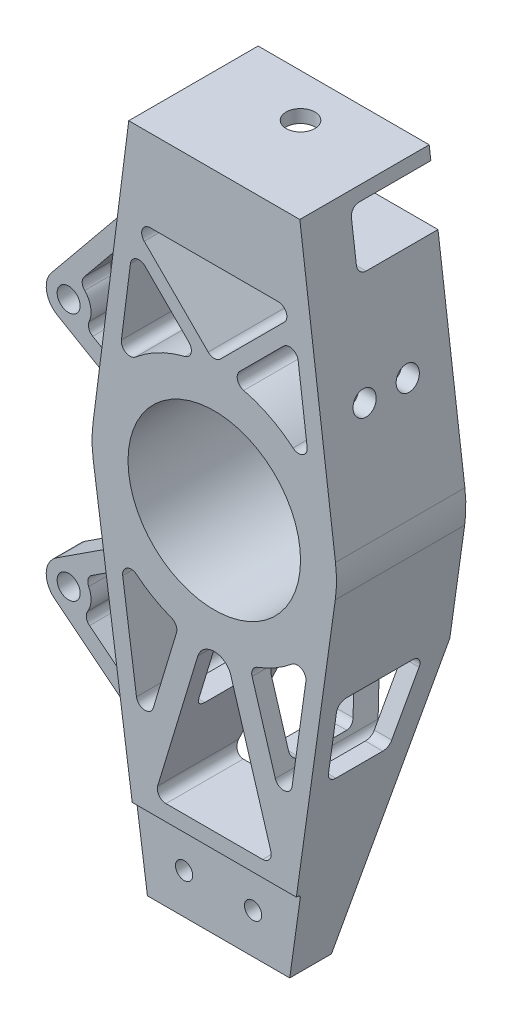
from build123d import *

# Parameters (mm, degrees)
SKETCH1_R                      = 30
SKETCH1_R_2                    = 3
BOSS_EXTRUDE1_DEPTH            = 22.5
CUT_EXTRUDE1_START             = 6.7
SKETCH2_W                      = 43.5
SKETCH2_H                      = 28
CUT_EXTRUDE1_DEPTH             = 45
CUT_EXTRUDE3_DEPTH             = 43.5
CUT_EXTRUDE3_DEPTH_BACK        = 43.5
SKETCH7_R                      = 5
CUT_EXTRUDE4_DEPTH             = 28.5
CUT_EXTRUDE5_REACH             = 44.5
CUT_EXTRUDE5_DIRECTION_2_DEPTH = 43.5
CUT_EXTRUDE6_START             = 30.728059
SKETCH10_R                     = 4
CUT_EXTRUDE6_DEPTH             = 7.070855
SKETCH12_R                     = 4
BOSS_EXTRUDE2_DEPTH            = 10


with BuildPart() as part:
    # Sketch1 → Boss-Extrude1 (new body, symmetric)
    with BuildSketch(Plane.XY):
        with BuildLine():
            Line((-29.75, 102.5), (-42.157330806, 5.38604301))
            ThreePointArc((-42.157330806, 5.38604301), (-42.499156405, -0.267777651), (-42.086113863, -5.916842057))
            Line((-42.086113863, -5.916842057), (-37.836662433, -36.142914512))
            Line((-37.836662433, -36.142914512), (-30.179572712, -90.607297158))
            Line((-30.179572712, -90.607297158), (-24.75, -129.227495762))
            Line((-24.75, -129.227495762), (24.75, -129.227495762))
            Line((24.75, -129.227495762), (42.086113863, -5.916842057))
            ThreePointArc((42.086113863, -5.916842057), (42.499156405, -0.267777651), (42.157330806, 5.38604301))
            Line((42.157330806, 5.38604301), (29.75, 102.5))
            Line((29.75, 102.5), (-29.75, 102.5))
        make_face()
        Circle(SKETCH1_R, mode=Mode.SUBTRACT)
        with Locations((-12, -115.227495762)):
            Circle(SKETCH1_R_2, mode=Mode.SUBTRACT)
        with Locations((12, -115.227495762)):
            Circle(SKETCH1_R_2, mode=Mode.SUBTRACT)
        with BuildLine():
            Line((-31.858021287, -35.571287293), (-27.062097865, -69.684379585))
            ThreePointArc((-27.062097865, -69.684379585), (-24.322273449, -72.257816506), (-21.219861823, -70.135492892))
            Line((-21.219861823, -70.135492892), (-13.147714601, -43.455581929))
            ThreePointArc((-13.147714601, -43.455581929), (-13.329157036, -41.258708643), (-14.96295738, -39.778887698))
            ThreePointArc((-14.96295738, -39.778887698), (-21.258144353, -36.801376315), (-26.982583804, -32.835806237))
            ThreePointArc((-26.982583804, -32.835806237), (-30.355185437, -32.537308543), (-31.858021287, -35.571287293))
        make_face(mode=Mode.SUBTRACT)
        with BuildLine():
            Line((31.858021287, -35.571287293), (27.062097865, -69.684379585))
            ThreePointArc((27.062097865, -69.684379585), (24.322273449, -72.257816506), (21.219861823, -70.135492892))
            Line((21.219861823, -70.135492892), (13.147714601, -43.455581929))
            ThreePointArc((13.147714601, -43.455581929), (13.329157036, -41.258708643), (14.96295738, -39.778887698))
            ThreePointArc((14.96295738, -39.778887698), (21.258144353, -36.801376315), (26.982583804, -32.835806237))
            ThreePointArc((26.982583804, -32.835806237), (30.355185437, -32.537308543), (31.858021287, -35.571287293))
        make_face(mode=Mode.SUBTRACT)
        with BuildLine():
            Line((-29.161510987, 59.761597506), (-32.303727483, 35.167018507))
            ThreePointArc((-32.303727483, 35.167018507), (-30.762779632, 32.152217955), (-27.394207157, 32.493190275))
            ThreePointArc((-27.394207157, 32.493190275), (-19.319896855, 37.85487532), (-10.240768442, 41.247747353))
            ThreePointArc((-10.240768442, 41.247747353), (-8.073152856, 43.356204158), (-8.842325871, 46.280673392))
            Line((-8.842325871, 46.280673392), (-24.064379057, 61.502726578))
            ThreePointArc((-24.064379057, 61.502726578), (-27.155452685, 62.220345925), (-29.161510987, 59.761597506))
        make_face(mode=Mode.SUBTRACT)
        with BuildLine():
            Line((29.161510987, 59.761597506), (32.303727483, 35.167018507))
            ThreePointArc((32.303727483, 35.167018507), (30.762779632, 32.152217955), (27.394207157, 32.493190275))
            ThreePointArc((27.394207157, 32.493190275), (19.319896855, 37.85487532), (10.240768442, 41.247747353))
            ThreePointArc((10.240768442, 41.247747353), (8.073152856, 43.356204158), (8.842325871, 46.280673392))
            Line((8.842325871, 46.280673392), (24.064379057, 61.502726578))
            ThreePointArc((24.064379057, 61.502726578), (27.155452685, 62.220345925), (29.161510987, 59.761597506))
        make_face(mode=Mode.SUBTRACT)
        with BuildLine():
            Line((-22.24794398, 74), (22.24794398, 74))
            ThreePointArc((22.24794398, 74), (25.019582578, 72.148050297), (24.369264324, 68.878679656))
            Line((24.369264324, 68.878679656), (2.121320344, 46.630735676))
            ThreePointArc((2.121320344, 46.630735676), (0, 45.75205602), (-2.121320344, 46.630735676))
            Line((-2.121320344, 46.630735676), (-24.369264324, 68.878679656))
            ThreePointArc((-24.369264324, 68.878679656), (-25.019582578, 72.148050297), (-22.24794398, 74))
        make_face(mode=Mode.SUBTRACT)
        with BuildLine():
            Line((-16.818119733, -96.727495762), (16.818119733, -96.727495762))
            ThreePointArc((16.818119733, -96.727495762), (19.227094436, -95.515466925), (19.689571267, -92.858723015))
            Line((19.689571267, -92.858723015), (5.742903069, -46.762454507))
            ThreePointArc((5.742903069, -46.762454507), (0, -42.5), (-5.742903069, -46.762454507))
            Line((-5.742903069, -46.762454507), (-19.689571267, -92.858723015))
            ThreePointArc((-19.689571267, -92.858723015), (-19.227094436, -95.515466925), (-16.818119733, -96.727495762))
        make_face(mode=Mode.SUBTRACT)
    extrude(amount=BOSS_EXTRUDE1_DEPTH, both=True)

    # Sketch2 → Cut-Extrude1 (cut)
    with BuildSketch(Plane.XY.offset(22.5).offset(CUT_EXTRUDE1_START)):
        with Locations((0, -115.227495762)):
            Rectangle(SKETCH2_W, SKETCH2_H)
    extrude(amount=-CUT_EXTRUDE1_DEPTH, mode=Mode.SUBTRACT)

    # Sketch6 → Cut-Extrude3 (cut, two sides)
    with BuildSketch(Plane(origin=(0, 0, 0), x_dir=(0, 0, -1), z_dir=(1, 0, 0))) as cut_extrude3_sk:
        with BuildLine():
            Line((22.5, -102.227495762), (22, -102.227495762))
            ThreePointArc((22, -102.227495762), (21.292893219, -102.52038898), (21, -103.227495762))
            Line((21, -103.227495762), (21, -129.227495762))
            Line((21, -129.227495762), (22.5, -129.227495762))
            Line((22.5, -129.227495762), (22.5, -102.227495762))
        make_face()
        Polygon((6.5, -129.227495762), (-22.5, -42.52418893), (-22.5, -129.227495762), align=None)
        with BuildLine():
            Line((-22.5, 98), (2.5, 98))
            ThreePointArc((2.5, 98), (4.621320344, 97.121320344), (5.5, 95))
            Line((5.5, 95), (5.5, 81.5))
            ThreePointArc((5.5, 81.5), (4.621320344, 79.378679656), (2.5, 78.5))
            Line((2.5, 78.5), (-22.5, 78.5))
            Line((-22.5, 78.5), (-22.5, 98))
        make_face()
    extrude(amount=CUT_EXTRUDE3_DEPTH, mode=Mode.SUBTRACT)
    extrude(cut_extrude3_sk.sketch, amount=-CUT_EXTRUDE3_DEPTH_BACK, mode=Mode.SUBTRACT)

    # Sketch7 → Cut-Extrude4 (cut)
    with BuildSketch(Plane(origin=(0, 102.5, 0), x_dir=(1, 0, 0), z_dir=(0, 1, 0))):
        with Locations((0, -7.5)):
            Circle(SKETCH7_R)
    extrude(amount=-CUT_EXTRUDE4_DEPTH, mode=Mode.SUBTRACT)

    # Cut-Extrude5: up to this face of the body (flat: up to its plane)
    cut_extrude5_end = Plane(part.part.faces().sort_by_distance((-29.558383843, -51.928459306, -1.701595807))[0])
    # Sketch8 → Cut-Extrude5 (cut, up to the picked face)
    with BuildSketch(Plane(origin=(0, 0, 0), x_dir=(0, 0, -1), z_dir=(1, 0, 0)), mode=Mode.PRIVATE) as cut_extrude5_sk1:
        with BuildLine():
            Line((-9.5, -42.52418893), (13.5, -42.52418893))
            ThreePointArc((13.5, -42.52418893), (15.621320344, -43.402868586), (16.5, -45.52418893))
            Line((16.5, -45.52418893), (16.5, -65.52418893))
            ThreePointArc((16.5, -65.52418893), (15.621320344, -67.645509274), (13.5, -68.52418893))
            Line((13.5, -68.52418893), (-2.810520427, -68.52418893))
            ThreePointArc((-2.810520427, -68.52418893), (-4.563402269, -67.958815235), (-5.655595256, -66.475792428))
            Line((-5.655595256, -66.475792428), (-12.345074829, -46.475792428))
            ThreePointArc((-12.345074829, -46.475792428), (-11.934626305, -43.771307088), (-9.5, -42.52418893))
        make_face()
    cut_extrude5_tool1 = split(extrude(cut_extrude5_sk1.sketch, amount=-CUT_EXTRUDE5_REACH, mode=Mode.PRIVATE), bisect_by=cut_extrude5_end, keep=Keep.BOTH, mode=Mode.PRIVATE)
    add(cut_extrude5_tool1.solids().sort_by_distance((0, -54.840923, -3.502309))[0], mode=Mode.SUBTRACT)

    # Sketch8 → Cut-Extrude5 direction 2 (cut)
    with BuildSketch(Plane(origin=(0, 0, 0), x_dir=(0, 0, -1), z_dir=(1, 0, 0))):
        with BuildLine():
            Line((-9.5, -42.52418893), (13.5, -42.52418893))
            ThreePointArc((13.5, -42.52418893), (15.621320344, -43.402868586), (16.5, -45.52418893))
            Line((16.5, -45.52418893), (16.5, -65.52418893))
            ThreePointArc((16.5, -65.52418893), (15.621320344, -67.645509274), (13.5, -68.52418893))
            Line((13.5, -68.52418893), (-2.810520427, -68.52418893))
            ThreePointArc((-2.810520427, -68.52418893), (-4.563402269, -67.958815235), (-5.655595256, -66.475792428))
            Line((-5.655595256, -66.475792428), (-12.345074829, -46.475792428))
            ThreePointArc((-12.345074829, -46.475792428), (-11.934626305, -43.771307088), (-9.5, -42.52418893))
        make_face()
    extrude(amount=CUT_EXTRUDE5_DIRECTION_2_DEPTH, mode=Mode.SUBTRACT)

    # Sketch10 → Cut-Extrude6 (cut)
    with BuildSketch(Plane(origin=(0, 0, 0), x_dir=(0, 0, -1), z_dir=(1, 0, 0)).offset(CUT_EXTRUDE6_START)):
        with Locations((-7.5, 43.5)):
            Circle(SKETCH10_R)
        with Locations((7.5, 43.5)):
            Circle(SKETCH10_R)
    extrude(amount=CUT_EXTRUDE6_DEPTH, mode=Mode.SUBTRACT)

    # Sketch12 → Boss-Extrude2 (add)
    with BuildSketch(Plane.XY.offset(-4.1)):
        with BuildLine():
            Line((-63.920817999, -62.786011), (-30.318792525, -89.617035655))
            Line((-30.318792525, -89.617035655), (-32.358565194, -75.108264932))
            ThreePointArc((-32.358565194, -75.108264932), (-34.348162194, -77.062609365), (-37.086664818, -76.534819861))
            Line((-37.086664818, -76.534819861), (-51.789633557, -64.794583636))
            ThreePointArc((-51.789633557, -64.794583636), (-52.875842208, -62.949660087), (-52.455505303, -60.850396163))
            ThreePointArc((-52.455505303, -60.850396163), (-51.262914316, -57.067826683), (-52.084645666, -53.187767054))
            ThreePointArc((-52.084645666, -53.187767054), (-52.300290454, -51.05772258), (-51.040992939, -49.326317975))
            Line((-51.040992939, -49.326317975), (-41.1344423, -42.876832559))
            ThreePointArc((-41.1344423, -42.876832559), (-38.552217057, -42.543846422), (-36.682090701, -44.355308369))
            Line((-36.682090701, -44.355308369), (-38.168005588, -33.786092136))
            Line((-38.168005588, -33.786092136), (-63.309447087, -50.153985078))
            ThreePointArc((-63.309447087, -50.153985078), (-66.844675528, -56.313693053), (-63.920817999, -62.786011))
        make_face()
        with Locations((-59.053794922, -56.690759868)):
            Circle(SKETCH12_R, mode=Mode.SUBTRACT)
        with BuildLine():
            Line((-36.218004492, 51.874001562), (-33.455055427, 73.5))
            Line((-33.455055427, 73.5), (-65.093635199, 34.783075148))
            ThreePointArc((-65.093635199, 34.783075148), (-66.728495932, 28.454989682), (-62.974738262, 23.104593564))
            Line((-62.974738262, 23.104593564), (-41.489764294, 10.611181809))
            Line((-41.489764294, 10.611181809), (-40.091055493, 21.559076113))
            ThreePointArc((-40.091055493, 21.559076113), (-41.739026607, 19.249129901), (-44.574922211, 19.345858485))
            Line((-44.574922211, 19.345858485), (-50.680166251, 22.896029304))
            ThreePointArc((-50.680166251, 22.896029304), (-52.025088315, 24.561795427), (-51.917023287, 26.699998898))
            ThreePointArc((-51.917023287, 26.699998898), (-51.379093911, 31.239923724), (-53.477644512, 35.301496179))
            ThreePointArc((-53.477644512, 35.301496179), (-54.329987985, 37.265446978), (-53.655986769, 39.297518457))
            Line((-53.655986769, 39.297518457), (-41.516831569, 54.152507619))
            ThreePointArc((-41.516831569, 54.152507619), (-38.008728255, 55.01019843), (-36.218004492, 51.874001562))
        make_face()
        with Locations((-59.053794922, 29.847456703)):
            Circle(SKETCH12_R, mode=Mode.SUBTRACT)
    extrude(amount=-BOSS_EXTRUDE2_DEPTH)


with BuildPart() as body_2:
    # Mirror1: mirrored copy
    add(part.part.mirror(Plane.XY))


solid = body_2.part
